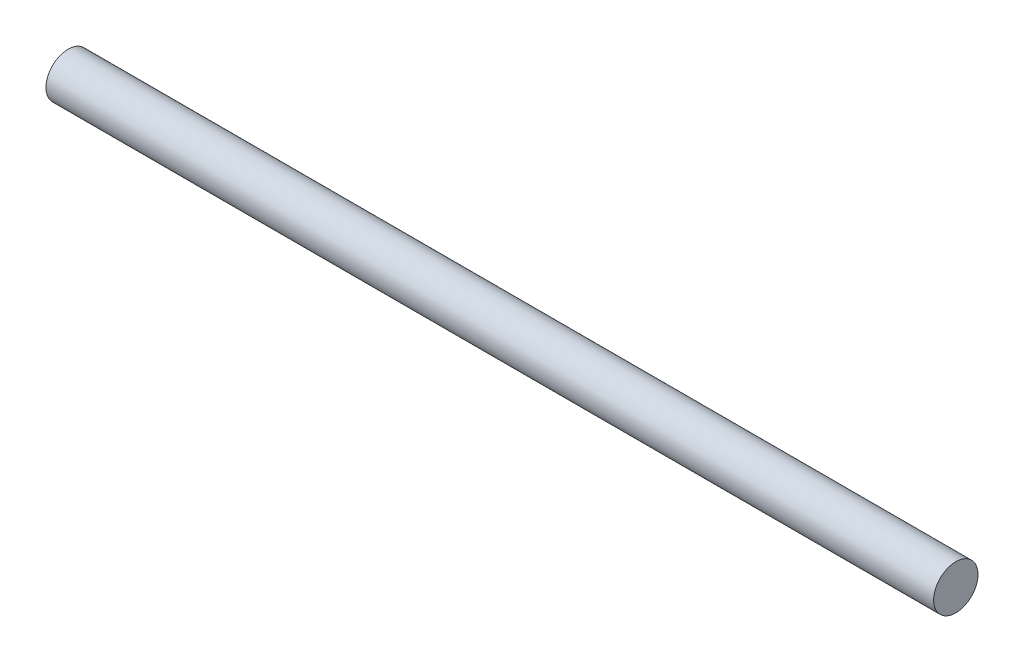
from build123d import *

# Parameters (mm, degrees)
SKETCH1_R           = 0.75
BOSS_EXTRUDE1_DEPTH = 30


with BuildPart() as part:
    # Sketch1 → Boss-Extrude1 (new body)
    with BuildSketch(Plane(origin=(0, 0, 0), x_dir=(0, 0, -1), z_dir=(1, 0, 0))):
        with Locations((-22.694500217, 11.062992171)):
            Circle(SKETCH1_R)
    extrude(amount=BOSS_EXTRUDE1_DEPTH)


solid = part.part
